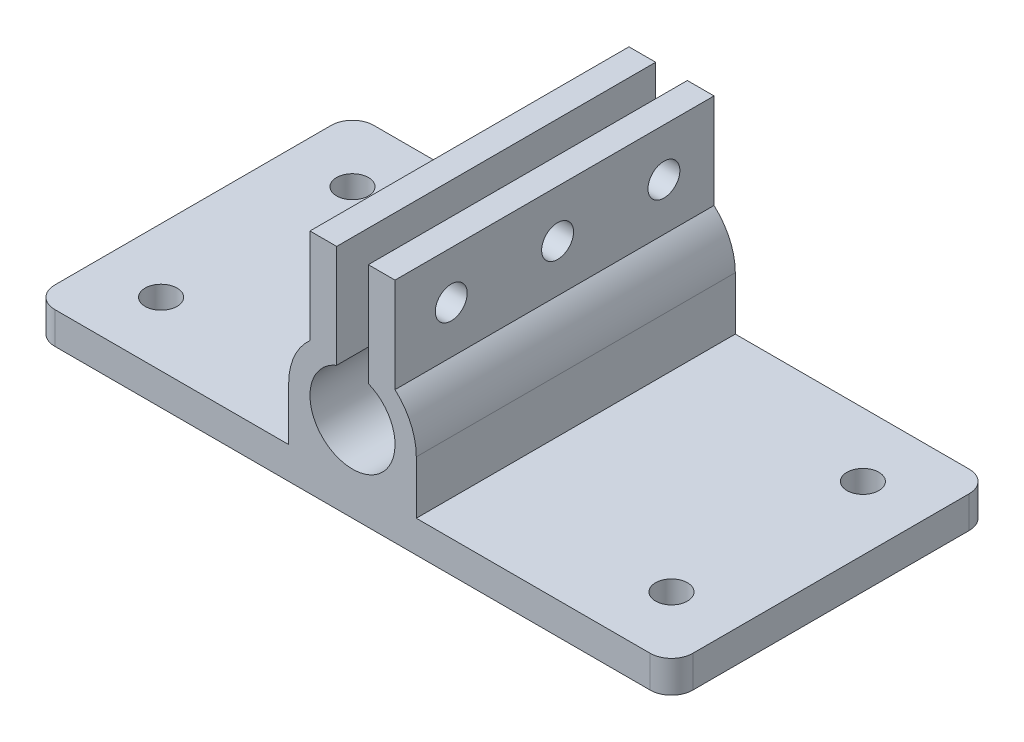
from build123d import *

# Parameters (mm, degrees)
SKETCH_1_W               = 60
SKETCH_1_H               = 30
EXTRUDE_1_DEPTH          = 3
SKETCH_2_R               = 1.5
CUT_EXTRUDE_1_DEPTH      = 3
MIRROR_2_COPY_1_SKETCH_R = 1.5
MIRROR_2_COPY_1_DEPTH    = 3
FILLET_2_R               = 2
SKETCH_5_R               = 6
EXTRUDE_2_DEPTH          = 30
SKETCH_6_W               = 12
SKETCH_6_H               = 5
EXTRUDE_3_DEPTH          = 30
SKETCH_7_R               = 4
CUT_EXTRUDE_4_DEPTH      = 31
SKETCH_8_W               = 8
SKETCH_8_H               = 9.1545719
EXTRUDE_4_DEPTH          = 30
SKETCH_9_W               = 2.976845738
SKETCH_9_H               = 12.85930144
CUT_EXTRUDE_5_DEPTH      = 31
SKETCH_10_R              = 1.5
CUT_EXTRUDE_6_DEPTH      = 35


with BuildPart() as part:
    # 草图1 → 凸台-拉伸1 (new body)
    with BuildSketch(Plane(origin=(0, 0, 0), x_dir=(1, 0, 0), z_dir=(0, 1, 0))):
        Rectangle(SKETCH_1_W, SKETCH_1_H)
    extrude(amount=EXTRUDE_1_DEPTH)

    # 草图2 → 切除-拉伸1 (cut)
    with BuildSketch(Plane(origin=(0, 3, 0), x_dir=(1, 0, 0), z_dir=(0, 1, 0))):
        with Locations((-24, -9)):
            Circle(SKETCH_2_R)
    cut_extrude_1 = extrude(amount=-CUT_EXTRUDE_1_DEPTH, mode=Mode.SUBTRACT)

    # 镜向1: 切除-拉伸1 across plane
    add(cut_extrude_1.mirror(Plane.XY), mode=Mode.SUBTRACT)

    # 镜向2: 切除-拉伸1 across plane
    add(cut_extrude_1.mirror(Plane(origin=(0, 0, 0), x_dir=(0, 0, 1), z_dir=(1, 0, 0))), mode=Mode.SUBTRACT)

    # 镜向2 copy 1 sketch → 镜向2 copy 1 (cut)
    with BuildSketch(Plane(origin=(0, 3, 0), x_dir=(-1, 0, 0), z_dir=(0, 1, 0))):
        with Locations((-24, -9)):
            Circle(MIRROR_2_COPY_1_SKETCH_R)
    extrude(amount=-MIRROR_2_COPY_1_DEPTH, mode=Mode.SUBTRACT)

    # 圆角2
    fillet_2_edges = [part.edges().sort_by_distance(p)[0] for p in [
        (-30, 1.5, -15),
        (30, 1.5, -15),
        (30, 1.5, 15),
        (-30, 1.5, 15),
    ]]
    fillet(fillet_2_edges, radius=FILLET_2_R)

    # 草图5 → 凸台-拉伸2 (add)
    with BuildSketch(Plane.XY.offset(15)):
        with Locations((0, 8)):
            Circle(SKETCH_5_R)
    extrude(amount=-EXTRUDE_2_DEPTH)

    # 草图6 → 凸台-拉伸3 (add)
    with BuildSketch(Plane.XY.offset(15)):
        with Locations((0, 5.5)):
            Rectangle(SKETCH_6_W, SKETCH_6_H)
    extrude(amount=-EXTRUDE_3_DEPTH)

    # 草图7 → 切除-拉伸4 (cut, through all)
    with BuildSketch(Plane.XY.offset(15)):
        with Locations((0, 8)):
            Circle(SKETCH_7_R)
    extrude(amount=-CUT_EXTRUDE_4_DEPTH, mode=Mode.SUBTRACT)

    # 草图8 → 凸台-拉伸4 (add)
    with BuildSketch(Plane.XY.offset(15)):
        with Locations((0, 16.818752798)):
            Rectangle(SKETCH_8_W, SKETCH_8_H)
    extrude(amount=-EXTRUDE_4_DEPTH)

    # 草图9 → 切除-拉伸5 (cut, through all)
    with BuildSketch(Plane.XY.offset(15)):
        with Locations((0, 16.396965649)):
            Rectangle(SKETCH_9_W, SKETCH_9_H)
    extrude(amount=-CUT_EXTRUDE_5_DEPTH, mode=Mode.SUBTRACT)

    # 草图10 → 切除-拉伸6 (cut, through all)
    with BuildSketch(Plane(origin=(4, 0, 0), x_dir=(0, 0, -1), z_dir=(1, 0, 0))):
        with Locations((10.28698243, 16.934087351)):
            Circle(SKETCH_10_R)
        with Locations((0.28698243, 16.934087351)):
            Circle(SKETCH_10_R)
        with Locations((-9.71301757, 16.934087351)):
            Circle(SKETCH_10_R)
    extrude(amount=-CUT_EXTRUDE_6_DEPTH, mode=Mode.SUBTRACT)


solid = part.part
